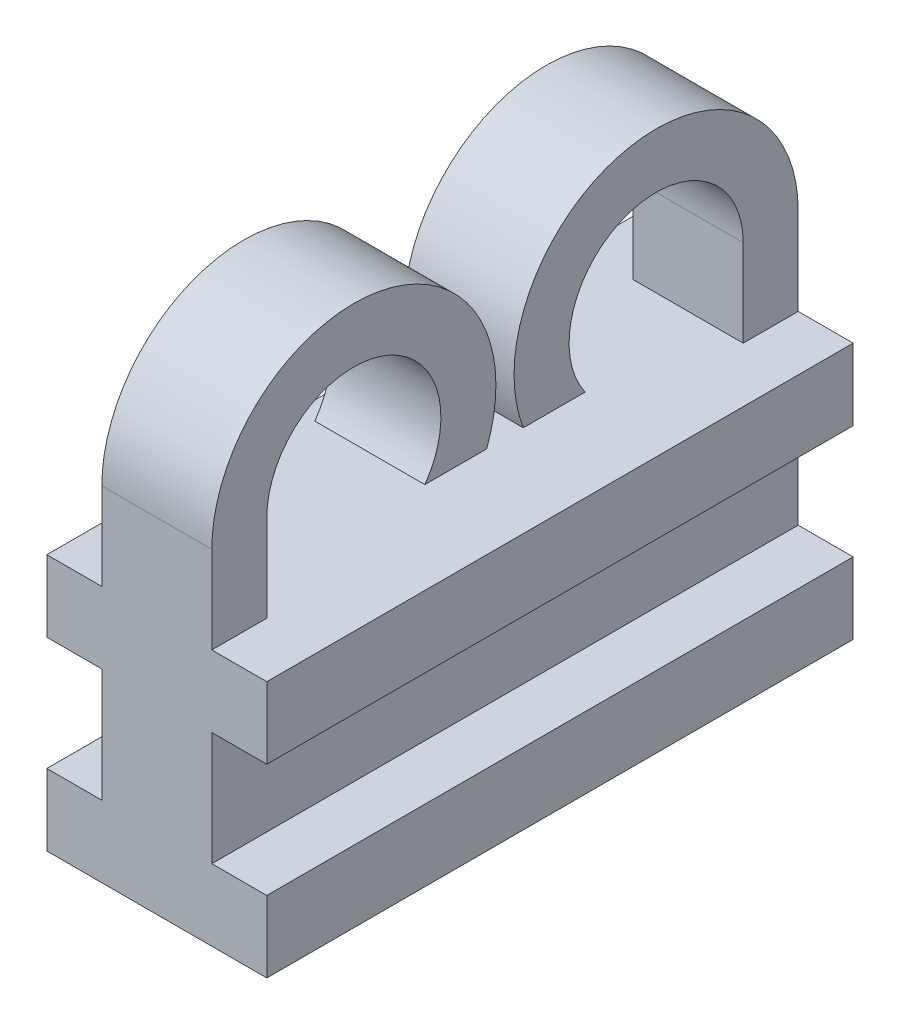
from build123d import *

# Parameters (mm, degrees)
SKETCH1_W           = 15.995688374
SKETCH1_H           = 2
SKETCH1_H_2         = 3
BOSS_EXTRUDE1_DEPTH = 3
SKETCH4_W           = 15.995688374
SKETCH4_H           = 1.95
BOSS_EXTRUDE2_DEPTH = 3


with BuildPart() as part:
    # Sketch1 → Boss-Extrude1 (new body)
    with BuildSketch(Plane(origin=(0, 0, 0), x_dir=(0, 0, -1), z_dir=(1, 0, 0))):
        with BuildLine():
            Line((-7.997844187, 0), (-6.497844187, 0))
            Line((-6.497844187, 0), (-6.497844187, 2.375))
            ThreePointArc((-6.497844187, 2.375), (-3.401228889, 4.637718799), (-2.186352513, 1))
            Line((-2.186352513, 1), (-0.5, 1))
            ThreePointArc((-0.5, 1), (-3.423879317, 6.186439769), (-7.997844187, 2.375))
            Line((-7.997844187, 2.375), (-7.997844187, 0))
        make_face()
        with Locations((0, -1)):
            Rectangle(SKETCH1_W, SKETCH1_H)
        with BuildLine():
            Line((6.497844187, 2.375), (6.497844187, 0))
            Line((6.497844187, 0), (7.997844187, 0))
            Line((7.997844187, 0), (7.997844187, 2.375))
            ThreePointArc((7.997844187, 2.375), (3.423879317, 6.186439769), (0.5, 1))
            Line((0.5, 1), (2.186352513, 1))
            ThreePointArc((2.186352513, 1), (3.401228889, 4.637718799), (6.497844187, 2.375))
        make_face()
        with Locations((0, -3.5)):
            Rectangle(SKETCH1_W, SKETCH1_H_2)
        with Locations((0, -6)):
            Rectangle(SKETCH1_W, SKETCH1_H)
    extrude(amount=BOSS_EXTRUDE1_DEPTH)

    # Sketch4 → Boss-Extrude2 (add, symmetric)
    with BuildSketch(Plane(origin=(1.5, 0, 0), x_dir=(0, 0, -1), z_dir=(1, 0, 0))):
        with Locations((0, -0.975)):
            Rectangle(SKETCH4_W, SKETCH4_H)
        with Locations((0, -6.025)):
            Rectangle(SKETCH4_W, SKETCH4_H)
    extrude(amount=BOSS_EXTRUDE2_DEPTH, both=True)


solid = part.part
